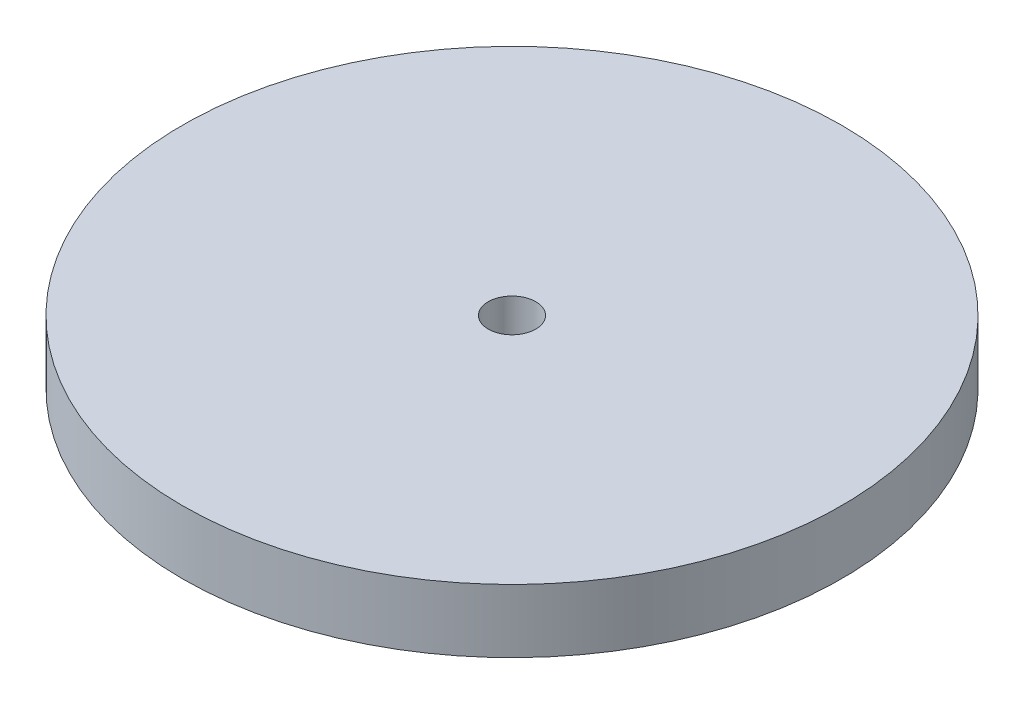
from build123d import *

# Parameters (mm, degrees)
SKETCH1_R           = 66.04
BOSS_EXTRUDE1_DEPTH = 12.7
SKETCH2_R           = 4.7625
CUT_EXTRUDE1_DEPTH  = 12.7


with BuildPart() as part:
    # Sketch1 → Boss-Extrude1 (new body)
    with BuildSketch(Plane(origin=(0, 0, 0), x_dir=(1, 0, 0), z_dir=(0, 1, 0))):
        Circle(SKETCH1_R)
    extrude(amount=BOSS_EXTRUDE1_DEPTH)

    # Sketch2 → Cut-Extrude1 (cut)
    with BuildSketch(Plane(origin=(0, 12.7, 0), x_dir=(1, 0, 0), z_dir=(0, 1, 0))):
        Circle(SKETCH2_R)
    extrude(amount=-CUT_EXTRUDE1_DEPTH, mode=Mode.SUBTRACT)


solid = part.part
